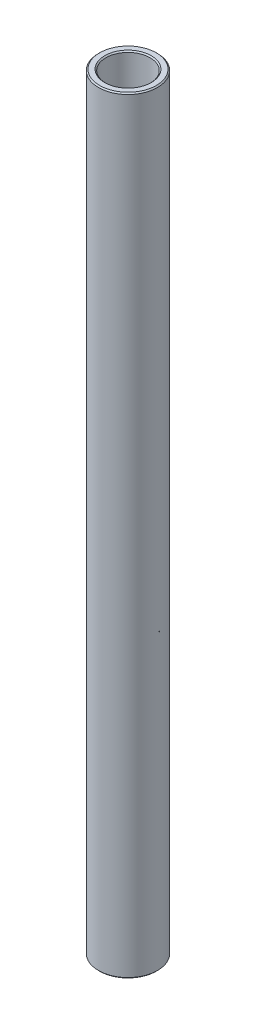
from build123d import *

# Parameters (mm, degrees)
SKETCH1_W     = 1.5875
SKETCH1_H     = 165.1
CHAMFER1_SIZE = 0.254


with BuildPart() as part:
    # Sketch1 → Revolve1 (revolve)
    with BuildSketch(Plane.XY):
        with Locations((5.55625, 0)):
            Rectangle(SKETCH1_W, SKETCH1_H)
    revolve(axis=Axis((0, 11.60859375, 0), (0, -1, 0)))

    # Chamfer1
    chamfer1_edges = [part.edges().sort_by_distance(p)[0] for p in [
        (-4.7625, -82.55, 0),
        (-6.35, -82.55, 0),
        (-6.35, 82.55, 0),
        (-4.7625, 82.55, 0),
    ]]
    chamfer(chamfer1_edges, length=CHAMFER1_SIZE)


solid = part.part
